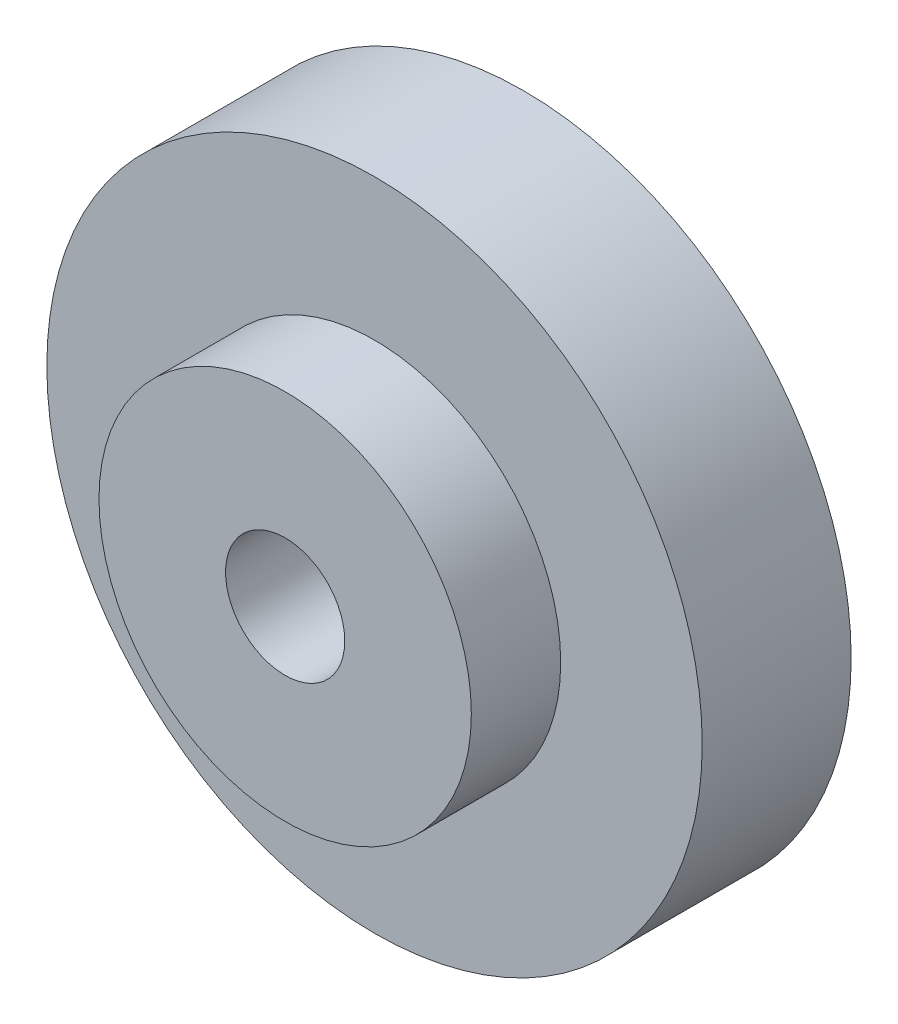
from build123d import *

# Parameters (mm, degrees)
SKETCH1_R           = 22
SKETCH1_R_2         = 4
BOSS_EXTRUDE1_DEPTH = 10
SKETCH2_R           = 12.5
SKETCH2_R_2         = 4
BOSS_EXTRUDE2_DEPTH = 6


with BuildPart() as part:
    # Sketch1 → Boss-Extrude1 (new body)
    with BuildSketch(Plane.XY):
        Circle(SKETCH1_R)
        Circle(SKETCH1_R_2, mode=Mode.SUBTRACT)
    extrude(amount=BOSS_EXTRUDE1_DEPTH)

    # Sketch2 → Boss-Extrude2 (add)
    with BuildSketch(Plane.XY.offset(10)):
        Circle(SKETCH2_R)
        Circle(SKETCH2_R_2, mode=Mode.SUBTRACT)
    extrude(amount=BOSS_EXTRUDE2_DEPTH)


solid = part.part
